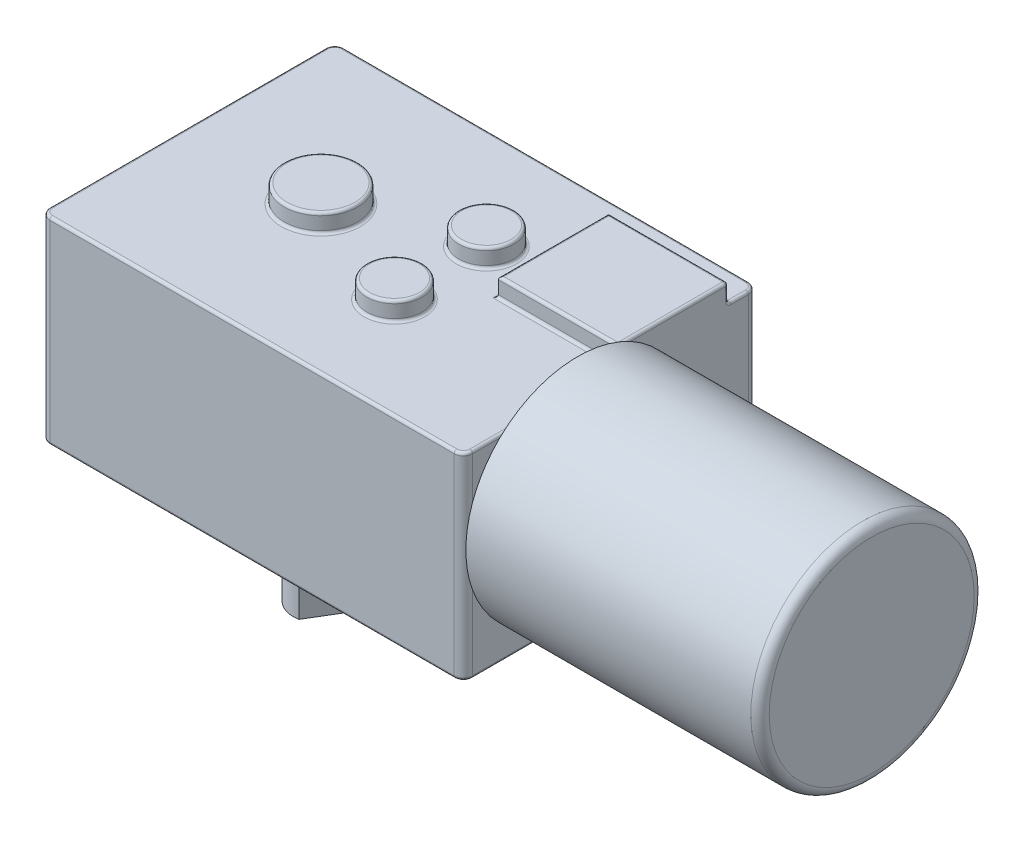
from build123d import *

# Parameters (mm, degrees)
SKETCH1_W           = 46
SKETCH1_H           = 32
BOSS_EXTRUDE1_DEPTH = 21.5
FILLET1_R           = 1
SKETCH2_W           = 13
SKETCH2_H           = 12
BOSS_EXTRUDE2_DEPTH = 2
SKETCH3_R           = 4
SKETCH3_R_2         = 3
BOSS_EXTRUDE3_DEPTH = 2
SKETCH4_R           = 6.75
SKETCH4_R_2         = 4
SKETCH4_R_3         = 1.5
SKETCH4_R_4         = 3
BOSS_EXTRUDE4_DEPTH = 2
FILLET2_R           = 0.3
SKETCH5_R           = 12.15
BOSS_EXTRUDE5_DEPTH = 32
FILLET3_R           = 1
SKETCH6_R           = 5
CUT_EXTRUDE1_DEPTH  = 0.1
SKETCH7_R           = 3
BOSS_EXTRUDE6_DEPTH = 14
CUT_EXTRUDE2_DEPTH  = 11


with BuildPart() as part:
    # Sketch1 → Boss-Extrude1 (new body)
    with BuildSketch(Plane(origin=(0, 0, 0), x_dir=(1, 0, 0), z_dir=(0, 1, 0))):
        Rectangle(SKETCH1_W, SKETCH1_H)
    extrude(amount=BOSS_EXTRUDE1_DEPTH)

    # Fillet1
    fillet1_edges = [part.edges().sort_by_distance(p)[0] for p in [
        (23, 10.75, 16),
        (-23, 10.75, 16),
        (-23, 10.75, -16),
        (23, 10.75, -16),
    ]]
    fillet(fillet1_edges, radius=FILLET1_R)

    # Sketch2 → Boss-Extrude2 (add)
    with BuildSketch(Plane(origin=(0, 21.5, 0), x_dir=(1, 0, 0), z_dir=(0, 1, 0))):
        with Locations((16.5, 6.8)):
            Rectangle(SKETCH2_W, SKETCH2_H)
    extrude(amount=BOSS_EXTRUDE2_DEPTH)

    # Sketch3 → Boss-Extrude3 (add)
    with BuildSketch(Plane(origin=(0, 21.5, 0), x_dir=(1, 0, 0), z_dir=(0, 1, 0))):
        with Locations((-8.5, 0)):
            Circle(SKETCH3_R)
        with Locations((4.5, 5)):
            Circle(SKETCH3_R_2)
        with Locations((4.5, -5)):
            Circle(SKETCH3_R_2)
    extrude(amount=BOSS_EXTRUDE3_DEPTH)

    # Sketch4 → Boss-Extrude4 (add)
    with BuildSketch(Plane.XZ):
        with Locations((-8.5, 0)):
            Circle(SKETCH4_R)
        with Locations((-16.4, 9.4)):
            Circle(SKETCH4_R_2)
        with Locations((-16.4, 9.4)):
            Circle(SKETCH4_R_3, mode=Mode.SUBTRACT)
        with Locations((-16.4, -9.4)):
            Circle(SKETCH4_R_2)
        with Locations((-16.4, -9.4)):
            Circle(SKETCH4_R_3, mode=Mode.SUBTRACT)
        with Locations((16.4, -9.4)):
            Circle(SKETCH4_R_2)
        with Locations((16.4, -9.4)):
            Circle(SKETCH4_R_3, mode=Mode.SUBTRACT)
        with Locations((16.4, 9.4)):
            Circle(SKETCH4_R_2)
        with Locations((16.4, 9.4)):
            Circle(SKETCH4_R_3, mode=Mode.SUBTRACT)
        with Locations((4.5, 5)):
            Circle(SKETCH4_R_4)
        with Locations((4.5, -5)):
            Circle(SKETCH4_R_4)
    extrude(amount=BOSS_EXTRUDE4_DEPTH)

    # Fillet2
    fillet2_edges = [part.edges().sort_by_distance(p)[0] for p in [
        (1.5, -2, -5),
        (-23, 0, 0),
        (-23, 21.5, 0),
        (23, 0, 0),
        (0, 0, 16),
        (0, 0, -16),
        (22.707106781, 0, 15.707106781),
        (22.707106781, 0, -15.707106781),
        (-22.707106781, 0, 15.707106781),
        (-22.707106781, 0, -15.707106781),
        (0, 21.5, -16),
        (23, 21.5, 7.1),
        (0, 21.5, 16),
        (22.707106781, 21.5, 15.707106781),
        (22.707106781, 21.5, -15.707106781),
        (-22.707106781, 21.5, 15.707106781),
        (-22.707106781, 21.5, -15.707106781),
        (23, 21.5, -13.9),
        (23, 22.5, -0.8),
        (16.5, 21.5, -12.8),
        (23, 22.5, -12.8),
        (10, 21.5, -6.8),
        (16.5, 21.5, -0.8),
        (23, 23.5, -6.8),
        (16.5, 23.5, -12.8),
        (10, 23.5, -6.8),
        (16.5, 23.5, -0.8),
        (-12.5, 21.5, 0),
        (-12.5, 23.5, 0),
        (1.5, 21.5, -5),
        (1.5, 23.5, -5),
        (1.5, 21.5, 5),
        (1.5, 23.5, 5),
        (-15.25, 0, 0),
        (-20.4, 0, 9.4),
        (-20.4, -2, 9.4),
        (-17.9, -2, 9.4),
        (-20.4, 0, -9.4),
        (-20.4, -2, -9.4),
        (-17.9, -2, -9.4),
        (12.4, 0, -9.4),
        (12.4, -2, -9.4),
        (14.9, -2, -9.4),
        (12.4, 0, 9.4),
        (12.4, -2, 9.4),
        (14.9, -2, 9.4),
        (1.5, 0, 5),
        (1.5, -2, 5),
        (1.5, 0, -5),
    ]]
    fillet(fillet2_edges, radius=FILLET2_R)

    # Sketch5 → Boss-Extrude5 (add)
    with BuildSketch(Plane(origin=(23, 0, 0), x_dir=(0, 0, -1), z_dir=(1, 0, 0))):
        with Locations((-3.584049663, 12.5)):
            Circle(SKETCH5_R)
    extrude(amount=BOSS_EXTRUDE5_DEPTH)

    # Fillet3
    fillet3_edges = [part.edges().sort_by_distance(p)[0] for p in [
        (55, 12.5, 15.734049663),
    ]]
    fillet(fillet3_edges, radius=FILLET3_R)

    # Sketch6 → Cut-Extrude1 (cut)
    with BuildSketch(Plane(origin=(0, -2, 0), x_dir=(1, 0, 0), z_dir=(0, 1, 0))):
        with Locations((-8.5, 0)):
            Circle(SKETCH6_R)
    extrude(amount=CUT_EXTRUDE1_DEPTH, mode=Mode.SUBTRACT)

    # Sketch7 → Boss-Extrude6 (add)
    with BuildSketch(Plane.XZ.offset(1.9)):
        with Locations((-8.5, 0)):
            Circle(SKETCH7_R)
    extrude(amount=BOSS_EXTRUDE6_DEPTH)

    # Sketch8 → Cut-Extrude2 (cut)
    with BuildSketch(Plane.XZ.offset(15.9)):
        Polygon((-7.939226328, 2.947122815), (-5.633433984, -0.884759447), (-2.324296826, 1.10647687), (-4.630089169, 4.938359132), align=None)
    extrude(amount=-CUT_EXTRUDE2_DEPTH, mode=Mode.SUBTRACT)


solid = part.part
